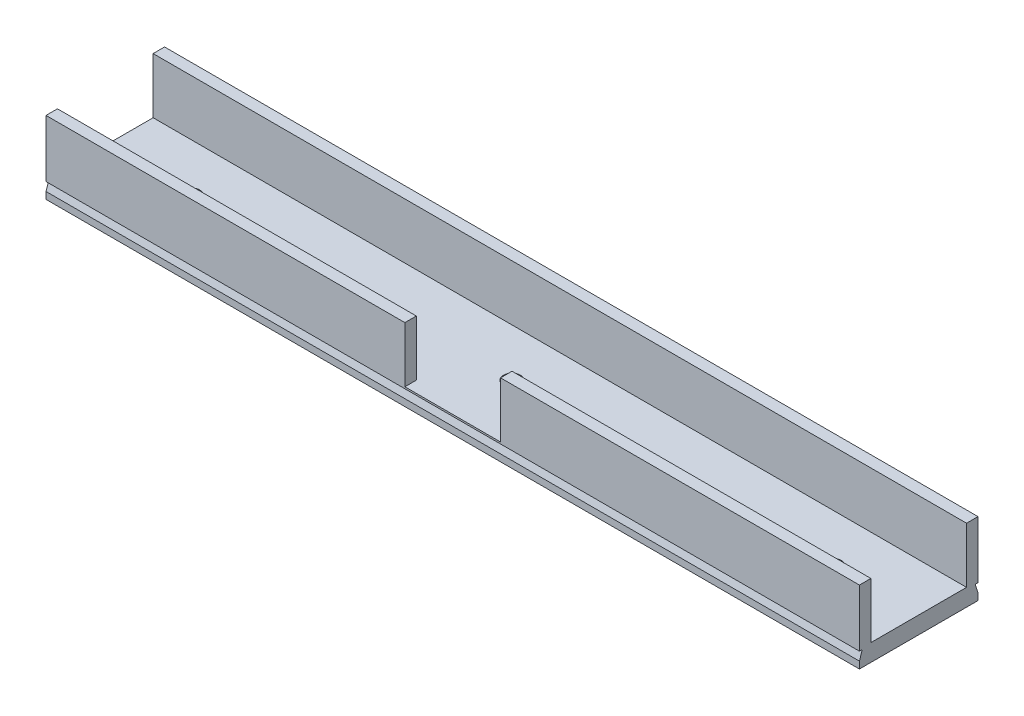
from build123d import *

# Parameters (mm, degrees)
CROQUIS1_W              = 142
CROQUIS1_H              = 20.7
SALIENTE_EXTRUIR2_DEPTH = 3
CROQUIS6_R              = 1.5
CORTAR_EXTRUIR4_DEPTH   = 3
CROQUIS7_W              = 142
CROQUIS7_H              = 2
SALIENTE_EXTRUIR3_DEPTH = 9.7
CORTAR_EXTRUIR5_DEPTH   = 224
CROQUIS10_W             = 16.7
CROQUIS10_H             = 9.7
CORTAR_EXTRUIR6_DEPTH   = 10


with BuildPart() as part:
    # Croquis1 → Saliente-Extruir2 (new body)
    with BuildSketch(Plane(origin=(0, 0, 0), x_dir=(1, 0, 0), z_dir=(0, 1, 0))):
        Rectangle(CROQUIS1_W, CROQUIS1_H)
    extrude(amount=SALIENTE_EXTRUIR2_DEPTH)

    # Croquis6 → Cortar-Extruir4 (cut)
    with BuildSketch(Plane(origin=(0, 3, 0), x_dir=(1, 0, 0), z_dir=(0, 1, 0))):
        with Locations((-56, 0)):
            Circle(CROQUIS6_R)
        Circle(CROQUIS6_R)
        with Locations((56, 0)):
            Circle(CROQUIS6_R)
    extrude(amount=-CORTAR_EXTRUIR4_DEPTH, mode=Mode.SUBTRACT)

    # Croquis7 → Saliente-Extruir3 (add)
    with BuildSketch(Plane(origin=(0, 3, 0), x_dir=(1, 0, 0), z_dir=(0, 1, 0))):
        with Locations((0, 9.35)):
            Rectangle(CROQUIS7_W, CROQUIS7_H)
        with Locations((0, -9.35)):
            Rectangle(CROQUIS7_W, CROQUIS7_H)
    extrude(amount=SALIENTE_EXTRUIR3_DEPTH)

    # Croquis9 → Cortar-Extruir5 (cut)
    with BuildSketch(Plane.ZY.offset(71)):
        Polygon((-10.35, 2.7), (-9.85, 2.7), (-10.35, 1.2), align=None)
        Polygon((10.35, 2.7), (9.85, 2.7), (10.35, 1.2), align=None)
    extrude(amount=-CORTAR_EXTRUIR5_DEPTH, mode=Mode.SUBTRACT)

    # Croquis10 → Cortar-Extruir6 (cut)
    with BuildSketch(Plane.XY.offset(10.35)):
        with Locations((0, 7.85)):
            Rectangle(CROQUIS10_W, CROQUIS10_H)
    extrude(amount=-CORTAR_EXTRUIR6_DEPTH, mode=Mode.SUBTRACT)


solid = part.part
